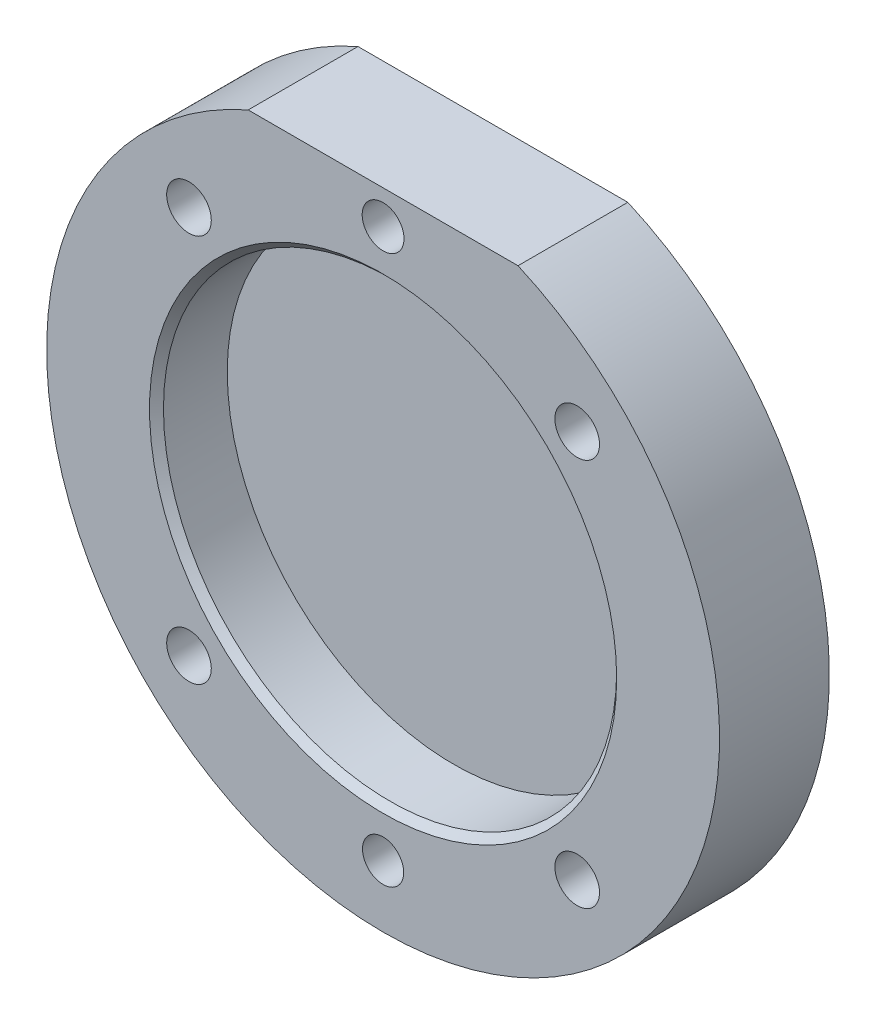
from build123d import *

# Parameters (mm, degrees)
BASE_EXTRUDE_DEPTH = 8.001
HOLE1_D            = 3.048
HOLE2_D            = 3.2512
CIRPATTERN1_COUNT  = 4
HOLE3_D            = 2.99974
SKETCH8_R          = 16.51
CUT_EXTRUDE1_DEPTH = 5.1562
CHAMFER1_SIZE      = 0.508


with BuildPart() as part:
    # Sketch1 → Base-Extrude (new body)
    with BuildSketch(Plane.XY):
        with BuildLine():
            Line((-9.8298, 22.4536), (9.8298, 22.4536))
            ThreePointArc((9.8298, 22.4536), (0, -24.511), (-9.8298, 22.4536))
        make_face()
    extrude(amount=BASE_EXTRUDE_DEPTH)

    # Hole1 (through all)
    with Locations(Plane.XY.offset(8.001)):
        with Locations((0, 19.99996)):
            Hole(HOLE1_D / 2)

    # Hole2 (through all)
    with Locations(Plane.XY.offset(8.001)):
        with Locations((-14.142107339, 14.142107339)):
            hole2 = Hole(HOLE2_D / 2)

    # CirPattern1: Hole2 ×4 about axis
    cirpattern1_axis = Axis((0, 0, 0), (0, 0, 1))
    for i in range(1, CIRPATTERN1_COUNT):
        add(hole2.rotate(cirpattern1_axis, i * 360 / CIRPATTERN1_COUNT), mode=Mode.SUBTRACT)

    # Hole3 (through all)
    with Locations(Plane.XY.offset(8.001)):
        with Locations((0, -20.0025)):
            Hole(HOLE3_D / 2)

    # Sketch8 → Cut-Extrude1 (cut)
    with BuildSketch(Plane.XY.offset(8.001)):
        Circle(SKETCH8_R)
    extrude(amount=-CUT_EXTRUDE1_DEPTH, mode=Mode.SUBTRACT)

    # Chamfer1
    chamfer1_edges = [part.edges().sort_by_distance(p)[0] for p in [
        (-16.51, 0, 8.001),
    ]]
    chamfer(chamfer1_edges, length=CHAMFER1_SIZE)


solid = part.part
